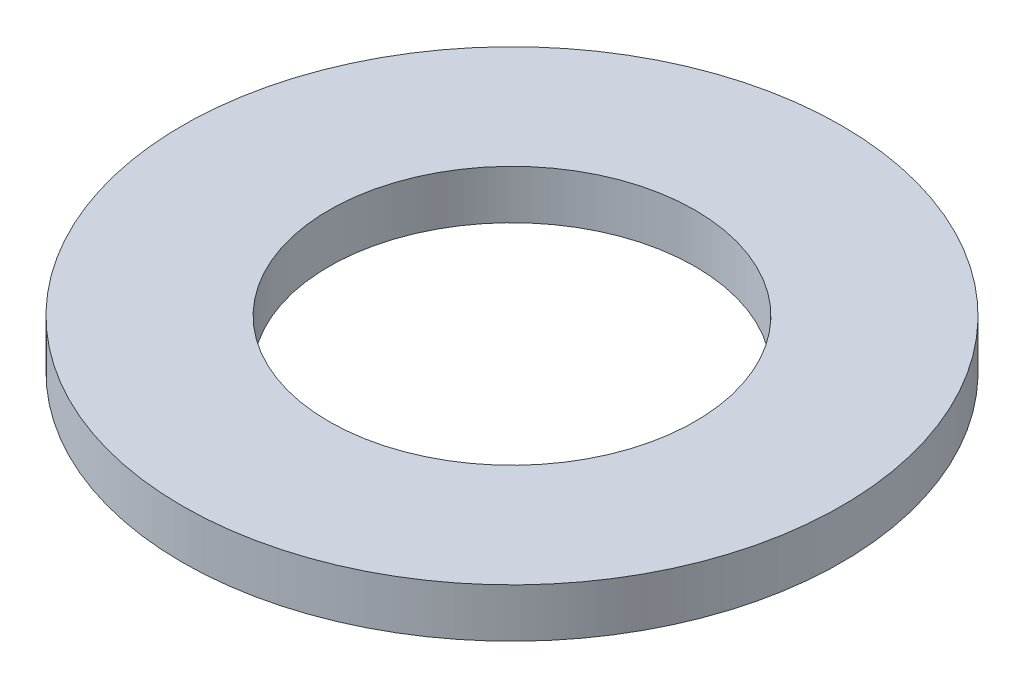
from build123d import *

# Parameters (mm, degrees)
ESQUISSE1_R      = 1.35
ESQUISSE1_R_2    = 0.75
EXTRUSION1_DEPTH = 0.2


with BuildPart() as part:
    # Esquisse1 → Extrusion1 (new body)
    with BuildSketch(Plane(origin=(0, 0, 0), x_dir=(1, 0, 0), z_dir=(0, 1, 0))):
        with Locations(Location((0, 0, 0), (0, 0, 270))):  # turned: the seam where the file's is
            Circle(ESQUISSE1_R)
        with Locations(Location((0, 0, 0), (0, 0, 270))):  # turned: the seam where the file's is
            Circle(ESQUISSE1_R_2, mode=Mode.SUBTRACT)
    extrude(amount=EXTRUSION1_DEPTH)


solid = part.part
